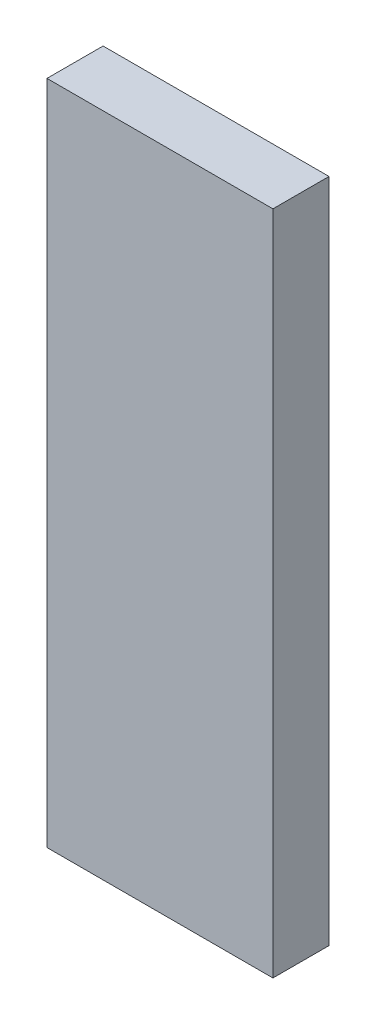
from build123d import *

# Parameters (mm, degrees)
SKETCH1_W           = 29
SKETCH1_H           = 7.2
BOSS_EXTRUDE1_DEPTH = 85.5


with BuildPart() as part:
    # Sketch1 → Boss-Extrude1 (new body)
    with BuildSketch(Plane(origin=(0, 0, 0), x_dir=(1, 0, 0), z_dir=(0, 1, 0))):
        Rectangle(SKETCH1_W, SKETCH1_H)
    extrude(amount=BOSS_EXTRUDE1_DEPTH)


solid = part.part
